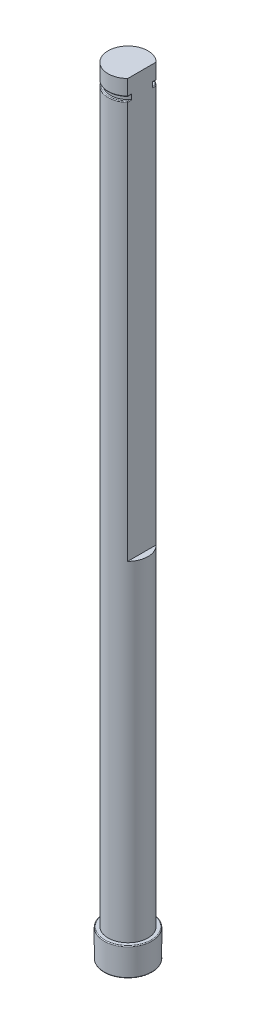
from build123d import *

# Parameters (mm, degrees)
SKETCH1_R           = 5
BOSS_EXTRUDE1_DEPTH = 195
CUT_EXTRUDE1_DEPTH  = 12
CUT_EXTRUDE2_START  = -105
CUT_EXTRUDE2_DEPTH  = 105
CUT_EXTRUDE3_START  = -5
CUT_EXTRUDE3_DEPTH  = 1
FILLET1_R           = 0.2
SKETCH5_R           = 6
SKETCH5_R_2         = 5
BOSS_EXTRUDE2_DEPTH = 7.05
FILLET2_R           = 0.2


with BuildPart() as part:
    # Sketch1 → Boss-Extrude1 (new body)
    with BuildSketch(Plane(origin=(0, 0, 0), x_dir=(1, 0, 0), z_dir=(0, 1, 0))):
        Circle(SKETCH1_R)
    extrude(amount=BOSS_EXTRUDE1_DEPTH)

    # Sketch1_3 → Cut-Extrude1 (cut)
    with BuildSketch(Plane(origin=(0, 0, 0), x_dir=(1, 0, 0), z_dir=(0, 1, 0))):
        with BuildLine():
            Line((1.842665061, -2.367400573), (1.842665061, 2.367400573))
            ThreePointArc((1.842665061, 2.367400573), (0.974114542, 2.837446186), (0, 3))
            ThreePointArc((0, 3), (-2.837446186, -0.974114542), (1.842665061, -2.367400573))
        make_face()
    extrude(amount=CUT_EXTRUDE1_DEPTH, mode=Mode.SUBTRACT)

    # Sketch3 → Cut-Extrude2 (cut)
    with BuildSketch(Plane(origin=(0, 195, 0), x_dir=(1, 0, 0), z_dir=(0, 1, 0)).offset(CUT_EXTRUDE2_START)):
        with BuildLine():
            ThreePointArc((5, 0), (4.609772229, 1.936491673), (3.5, 3.570714214))
            Line((3.5, 3.570714214), (3.5, -3.570714214))
            ThreePointArc((3.5, -3.570714214), (4.609772229, -1.936491673), (5, 0))
        make_face()
    extrude(amount=CUT_EXTRUDE2_DEPTH, mode=Mode.SUBTRACT)

    # Sketch4 → Cut-Extrude3 (cut)
    with BuildSketch(Plane(origin=(0, 195, 0), x_dir=(1, 0, 0), z_dir=(0, 1, 0)).offset(CUT_EXTRUDE3_START)):
        with BuildLine():
            Line((3.5, 2.666458325), (3.5, 3.570714214))
            ThreePointArc((3.5, 3.570714214), (-5, 0), (3.5, -3.570714214))
            Line((3.5, -3.570714214), (3.5, -2.666458325))
            ThreePointArc((3.5, -2.666458325), (-4.4, 0), (3.5, 2.666458325))
        make_face()
    extrude(amount=CUT_EXTRUDE3_DEPTH, mode=Mode.SUBTRACT)

    # Fillet1
    fillet1_edges = [part.edges().sort_by_distance(p)[0] for p in [
        (3.5, 191, 3.11858627),
        (3.5, 190, 3.11858627),
        (3.5, 191, -3.11858627),
        (3.5, 190, -3.11858627),
        (-5, 191, 0),
        (-5, 190, 0),
    ]]
    fillet(fillet1_edges, radius=FILLET1_R)

    # Sketch5 → Boss-Extrude2 (add)
    with BuildSketch(Plane.XZ):
        Circle(SKETCH5_R)
        Circle(SKETCH5_R_2, mode=Mode.SUBTRACT)
    extrude(amount=-BOSS_EXTRUDE2_DEPTH)

    # Fillet2
    fillet2_edges = [part.edges().sort_by_distance(p)[0] for p in [
        (-6, 7.05, 0),
        (-6, 0, 0),
    ]]
    fillet(fillet2_edges, radius=FILLET2_R)


solid = part.part
